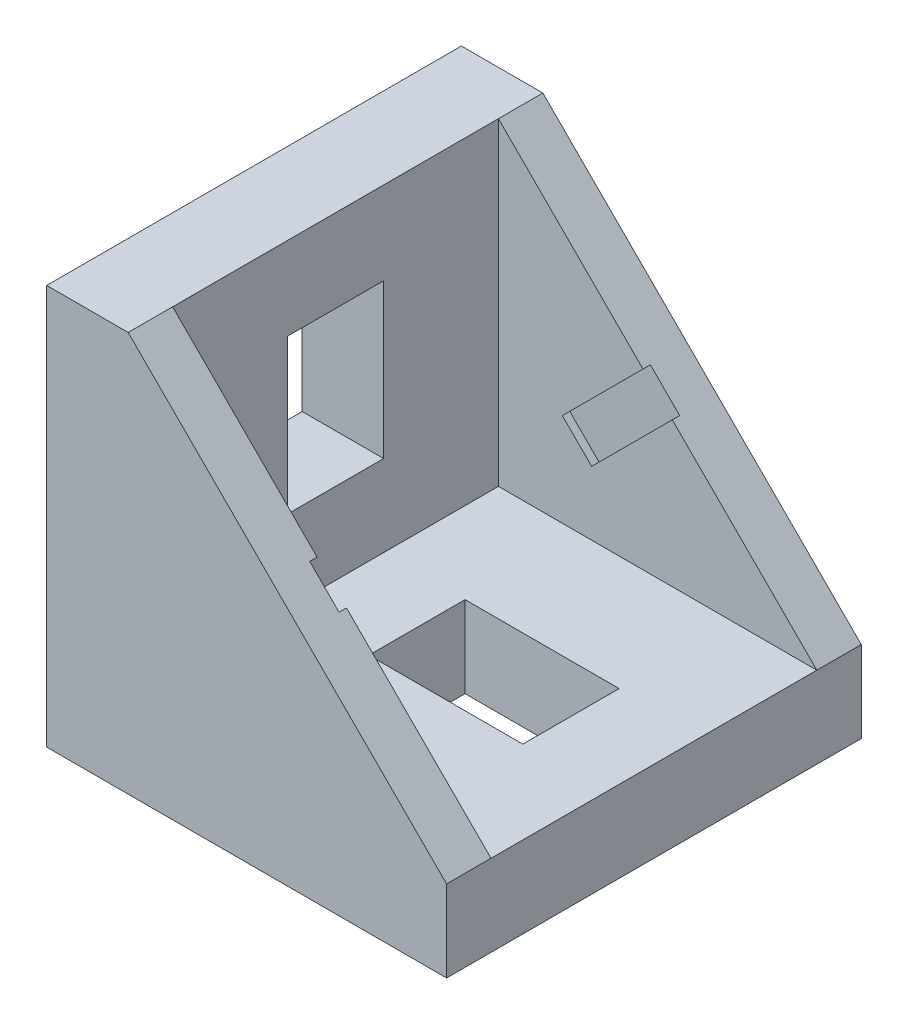
from build123d import *

# Parameters (mm, degrees)
BOSS_EXTRU_1_DEPTH      = 28
ESQUISSE2_W             = 21.5
ESQUISSE2_H             = 22
ENL_V_MAT_EXTRU_1_DEPTH = 21.5
ESQUISSE3_W             = 6.5
ESQUISSE3_H             = 10.4
ENL_V_MAT_EXTRU_2_DEPTH = 6.9
ESQUISSE4_W             = 10.4
ESQUISSE4_H             = 6.5
ENL_V_MAT_EXTRU_3_DEPTH = 18
ESQUISSE5_W             = 0.5
ESQUISSE5_H             = 2.8
ENL_V_MAT_EXTRU_4_DEPTH = 7.7
BOSS_EXTRU_2_DEPTH      = 3.9
BOSS_EXTRU_2_DEPTH_BACK = 3.9


with BuildPart() as part:
    # Esquisse1 → Boss.-Extru.1 (new body)
    with BuildSketch(Plane.XY):
        Polygon((0, 27), (0, 0), (27, 0), (27, 5.5), (5.5, 27), align=None)
    extrude(amount=BOSS_EXTRU_1_DEPTH)

    # Esquisse2 → Enlèv. mat.-Extru.1 (cut)
    with BuildSketch(Plane(origin=(0, 27, 0), x_dir=(1, 0, 0), z_dir=(0, 1, 0))):
        with Locations((16.25, -14)):
            Rectangle(ESQUISSE2_W, ESQUISSE2_H)
    extrude(amount=-ENL_V_MAT_EXTRU_1_DEPTH, mode=Mode.SUBTRACT)

    # Esquisse3 → Enlèv. mat.-Extru.2 (cut)
    with BuildSketch(Plane(origin=(5.5, 0, 0), x_dir=(0, 0, -1), z_dir=(1, 0, 0))):
        with Locations((-14, 16.2)):
            Rectangle(ESQUISSE3_W, ESQUISSE3_H)
    extrude(amount=-ENL_V_MAT_EXTRU_2_DEPTH, mode=Mode.SUBTRACT)

    # Esquisse4 → Enlèv. mat.-Extru.3 (cut)
    with BuildSketch(Plane(origin=(0, 5.5, 0), x_dir=(1, 0, 0), z_dir=(0, 1, 0))):
        with Locations((16.2, -14)):
            Rectangle(ESQUISSE4_W, ESQUISSE4_H)
    extrude(amount=-ENL_V_MAT_EXTRU_3_DEPTH, mode=Mode.SUBTRACT)

    # Esquisse5 → Enlèv. mat.-Extru.4 (cut)
    with BuildSketch(Plane(origin=(16.25, 16.25, 0), x_dir=(0, 0, -1), z_dir=(0.707106781, 0.707106781, 0))):
        with Locations((-25.25, 0)):
            Rectangle(ESQUISSE5_W, ESQUISSE5_H)
        with Locations((-2.75, 0)):
            Rectangle(ESQUISSE5_W, ESQUISSE5_H)
    extrude(amount=-ENL_V_MAT_EXTRU_4_DEPTH, mode=Mode.SUBTRACT)

    # Esquisse6 → Boss.-Extru.2 (add, two sides)
    with BuildSketch(Plane.XY.offset(14)) as boss_extru_2_sk:
        Polygon((0, 27), (-2.474873734, 24.525126266), (-1.414213562, 23.464466094), (1.060660172, 25.939339828), align=None)
        Polygon((0, 4.171930009), (-2.474873734, 1.697056275), (-1.414213562, 0.636396103), (1.060660172, 3.111269837), align=None)
        Polygon((3.111269837, 1.060660172), (0.636396103, -1.414213562), (1.697056275, -2.474873734), (4.171930009, 0), align=None)
        Polygon((25.939339828, 1.060660172), (23.464466094, -1.414213562), (24.525126266, -2.474873734), (27, 0), align=None)
    extrude(amount=BOSS_EXTRU_2_DEPTH)
    extrude(boss_extru_2_sk.sketch, amount=-BOSS_EXTRU_2_DEPTH_BACK)


solid = part.part
